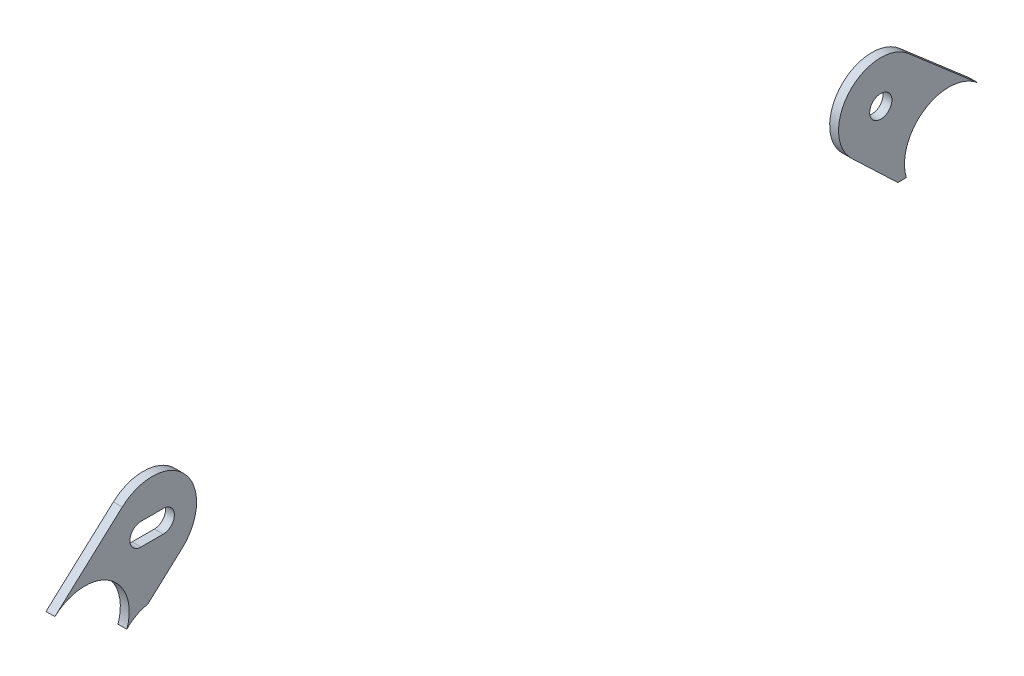
from build123d import *

# Parameters (mm, degrees)
BOSS_EXTRUDE1_DEPTH   = 2.54
SKETCH1_R             = 3.175
BOSS_EXTRUDE1_2_DEPTH = 2.54
CUT_EXTRUDE1_DEPTH    = 10
CUT_EXTRUDE2_DEPTH    = 10


with BuildPart() as part:
    # Sketch1 → Boss-Extrude1 (new body)
    with BuildSketch(Plane(origin=(0, 0, 0), x_dir=(0, 0, -1), z_dir=(1, 0, 0))):
        with BuildLine():
            Line((-132.173225325, -84.582396488), (-112.918972687, -67.080031215))
            ThreePointArc((-112.918972687, -67.080031215), (-94.978825746, -67.935091298), (-95.833885829, -85.875238239))
            Line((-95.833885829, -85.875238239), (-115.088138468, -103.377603512))
            ThreePointArc((-115.088138468, -103.377603512), (-114.233078385, -85.437456571), (-132.173225325, -84.582396488))
        make_face()
        with BuildLine():
            ThreePointArc((-107.551429258, -73.302634727), (-110.726429258, -76.477634727), (-107.551429258, -79.652634727))
            Line((-107.551429258, -79.652634727), (-101.201429258, -79.652634727))
            ThreePointArc((-101.201429258, -79.652634727), (-98.026429258, -76.477634727), (-101.201429258, -73.302634727))
            Line((-101.201429258, -73.302634727), (-107.551429258, -73.302634727))
        make_face(mode=Mode.SUBTRACT)
    extrude(amount=BOSS_EXTRUDE1_DEPTH)

    # Sketch5 → Cut-Extrude2 (cut)
    with BuildSketch(Plane(origin=(2.54, 0, 0), x_dir=(0, 0, -1), z_dir=(1, 0, 0))):
        with BuildLine():
            Line((-111.589308689, -98.016747612), (-113.403096994, -101.509044233))
            add(Edge.make_bspline(
                [(-111.589308689, -98.016747612), (-96.861818153, -81.266928915), (-67.096203504, -98.64520207), (-77.198124577, -118.095600298), (-87.300045651, -137.545998525), (-118.635496441, -123.190312645), (-113.403096994, -101.509044233)],
                knots=[0, 0, 0, 0, 0.5, 0.5, 0.5, 1, 1, 1, 1], degree=3, weights=[1, 0.385133254, 0.385133254, 1, 0.385133254, 0.385133254, 1]))
        make_face()
    extrude(amount=-CUT_EXTRUDE2_DEPTH, mode=Mode.SUBTRACT)


with BuildPart() as body_2:
    # Sketch1 → Boss-Extrude1 2 (new body)
    with BuildSketch(Plane(origin=(0, 0, 0), x_dir=(0, 0, -1), z_dir=(1, 0, 0))):
        with BuildLine():
            Line((95.540074367, -85.034535944), (114.582474398, -103.175308774))
            ThreePointArc((114.582474398, -103.175308774), (113.938329585, -85.444576189), (131.648348491, -84.372647625))
            Line((131.648348491, -84.372647625), (111.752654756, -67.172007853))
            ThreePointArc((111.752654756, -67.172007853), (94.928136795, -68.190339989), (95.540074367, -85.034535944))
        make_face()
        with Locations((103.862003689, -76.298992609)):
            Circle(SKETCH1_R, mode=Mode.SUBTRACT)
    extrude(amount=BOSS_EXTRUDE1_2_DEPTH)

    # Sketch4 → Cut-Extrude1 (cut)
    with BuildSketch(Plane(origin=(2.54, 0, 0), x_dir=(0, 0, -1), z_dir=(1, 0, 0))):
        Polygon((111.167984165, -97.595743227), (108.627984165, -97.595743227), (102.147549377, -97.595743227), (102.147549377, -107.314158184), (125.321864193, -107.314158184), (121.698336242, -97.595743227), align=None)
    extrude(amount=-CUT_EXTRUDE1_DEPTH, mode=Mode.SUBTRACT)


with BuildPart() as body_3:
    # of the pieces the cut leaves, the one that is kept (cut_extrude2_keep)
    add(part.part.solids().sort_by_distance((0, -84.582396488, 132.173225325))[0])


solid = Compound([body_2.part, body_3.part])
